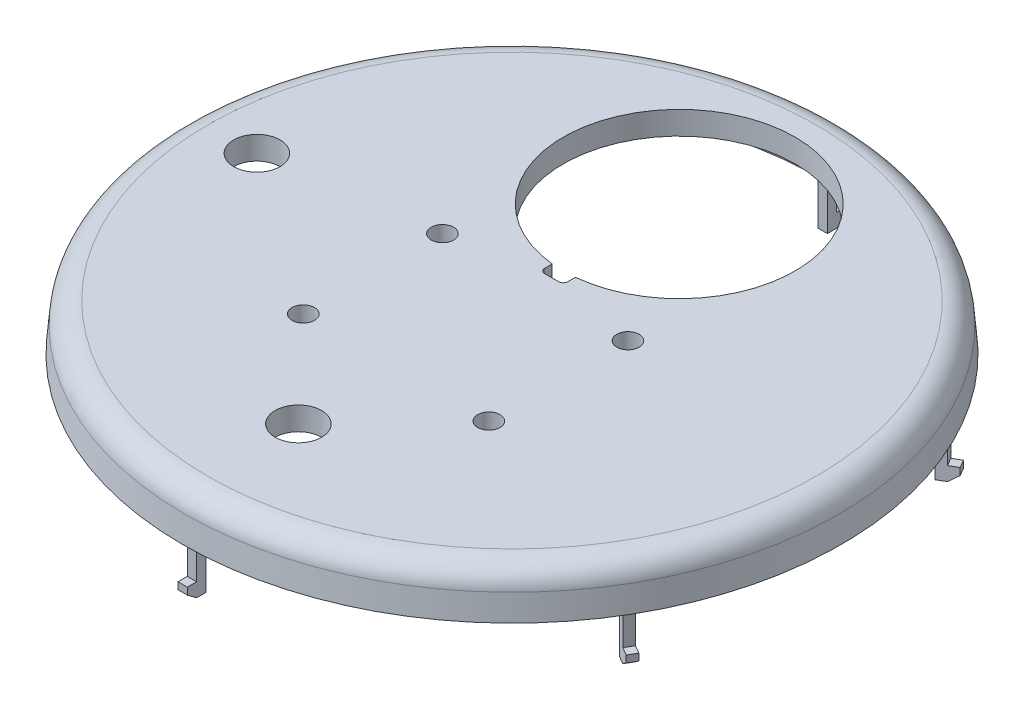
from build123d import *

# Parameters (mm, degrees)
SKETCH1_R           = 71.05
BOSS_EXTRUDE1_DEPTH = 10
BOSS_EXTRUDE1_TAPER = 5
SHELL4_T            = -5
SKETCH2_R           = 5
SKETCH2_R_2         = 25
SKETCH2_R_3         = 2.413
CUT_EXTRUDE1_DEPTH  = 101.976259737
CUT_EXTRUDE4_DEPTH  = 10
FILLET2_R           = 5
SKETCH11_R          = 5
CUT_EXTRUDE8_DEPTH  = 101.976259737
SKETCH12_W          = 2
SKETCH12_H          = 2
BOSS_EXTRUDE4_DEPTH = 7.5
SKETCH13_W          = 2
SKETCH13_H          = 4
BOSS_EXTRUDE5_DEPTH = 3
CUT_EXTRUDE9_DEPTH  = 3
CUT_EXTRUDE10_DEPTH = 3
CUT_EXTRUDE11_DEPTH = 3
CUT_EXTRUDE12_DEPTH = 3
CUT_EXTRUDE13_DEPTH = 3
CUT_EXTRUDE14_DEPTH = 3


with BuildPart() as part:
    # Sketch1 → Boss-Extrude1 (new body)
    with BuildSketch(Plane(origin=(0, 0, 0), x_dir=(1, 0, 0), z_dir=(0, 1, 0))):
        Circle(SKETCH1_R)
    extrude(amount=BOSS_EXTRUDE1_DEPTH, taper=BOSS_EXTRUDE1_TAPER)

    # Shell4
    shell4_openings = [part.faces().sort_by_distance(p)[0] for p in [
        (0, 0, 0),
    ]]
    offset(amount=SHELL4_T, openings=shell4_openings, kind=Kind.INTERSECTION)

    # Sketch2 → Cut-Extrude1 (cut, through all)
    with BuildSketch(Plane(origin=(0, 10, 0), x_dir=(1, 0, 0), z_dir=(0, 1, 0))):
        with Locations(Location((0, -46.05, 0), (0, 0, 270))):
            Circle(SKETCH2_R)
        with Locations(Location((0, 36.05, 0), (0, 0, 270))):
            Circle(SKETCH2_R_2)
        with Locations(Location((20, 5, 0), (0, 0, 270))):
            Circle(SKETCH2_R_3)
        with Locations(Location((20, -25, 0), (0, 0, 270))):
            Circle(SKETCH2_R_3)
        with Locations(Location((-20, -25, 0), (0, 0, 270))):
            Circle(SKETCH2_R_3)
        with Locations(Location((-20, 5, 0), (0, 0, 270))):
            Circle(SKETCH2_R_3)
    extrude(amount=-CUT_EXTRUDE1_DEPTH, mode=Mode.SUBTRACT)

    # Sketch6 → Cut-Extrude4 (cut)
    with BuildSketch(Plane(origin=(0, 10, 0), x_dir=(1, 0, 0), z_dir=(0, 1, 0))):
        with BuildLine():
            Line((-2.5, 14.187111582), (2.5, 14.187111582))
            Line((2.5, 14.187111582), (2.5, 9.55))
            ThreePointArc((2.5, 9.55), (2.207106781, 8.842893219), (1.5, 8.55))
            Line((1.5, 8.55), (-1.5, 8.55))
            ThreePointArc((-1.5, 8.55), (-2.207106781, 8.842893219), (-2.5, 9.55))
            Line((-2.5, 9.55), (-2.5, 14.187111582))
        make_face()
    extrude(amount=-CUT_EXTRUDE4_DEPTH, mode=Mode.SUBTRACT)

    # Fillet2
    fillet2_edges = [part.edges().sort_by_distance(p)[0] for p in [
        (-70.175113365, 10, 0),
    ]]
    fillet(fillet2_edges, radius=FILLET2_R)

    # Sketch11 → Cut-Extrude8 (cut, through all)
    with BuildSketch(Plane(origin=(0, 10, 0), x_dir=(1, 0, 0), z_dir=(0, 1, 0))):
        with Locations(Location((-55, 0, 0), (0, 0, 270))):
            Circle(SKETCH11_R)
    extrude(amount=-CUT_EXTRUDE8_DEPTH, mode=Mode.SUBTRACT)

    # Sketch12 → Boss-Extrude4 (add)
    with BuildSketch(Plane(origin=(0, 0, 0), x_dir=(-1, 0, 0), z_dir=(0, -1, 0))):
        Polygon((58.523702054, 32.633974596), (60.255752861, 33.633974596), (59.255752861, 35.366025404), (57.523702054, 34.366025404), align=None)
        with Locations((0, 68)):
            Rectangle(SKETCH12_W, SKETCH12_H)
        Polygon((57.523702054, -34.366025404), (59.255752861, -35.366025404), (60.255752861, -33.633974596), (58.523702054, -32.633974596), align=None)
        with Locations((0, -68)):
            Rectangle(SKETCH12_W, SKETCH12_H)
        Polygon((-58.523702054, -32.633974596), (-60.255752861, -33.633974596), (-59.255752861, -35.366025404), (-57.523702054, -34.366025404), align=None)
        Polygon((-57.523702054, 34.366025404), (-59.255752861, 35.366025404), (-60.255752861, 33.633974596), (-58.523702054, 32.633974596), align=None)
    extrude(amount=BOSS_EXTRUDE4_DEPTH)

    # Sketch13 → Boss-Extrude5 (add)
    with BuildSketch(Plane(origin=(0, -7.5, 0), x_dir=(-1, 0, 0), z_dir=(0, -1, 0))):
        Polygon((-58.523702054, -32.633974596), (-61.987803669, -34.633974596), (-60.987803669, -36.366025404), (-57.523702054, -34.366025404), align=None)
        with Locations((0, -69)):
            Rectangle(SKETCH13_W, SKETCH13_H)
        Polygon((-57.523702054, 34.366025404), (-60.987803669, 36.366025404), (-61.987803669, 34.633974596), (-58.523702054, 32.633974596), align=None)
        with Locations((0, 69)):
            Rectangle(SKETCH13_W, SKETCH13_H)
        Polygon((58.523702054, 32.633974596), (61.987803669, 34.633974596), (60.987803669, 36.366025404), (57.523702054, 34.366025404), align=None)
        Polygon((57.523702054, -34.366025404), (60.987803669, -36.366025404), (61.987803669, -34.633974596), (58.523702054, -32.633974596), align=None)
    extrude(amount=BOSS_EXTRUDE5_DEPTH)

    # Sketch14 → Cut-Extrude9 (cut)
    with BuildSketch(Plane(origin=(1, 0, 0), x_dir=(0, 0, -1), z_dir=(1, 0, 0))):
        Polygon((71, -9), (69, -10.5), (71, -10.5), align=None)
    extrude(amount=-CUT_EXTRUDE9_DEPTH, mode=Mode.SUBTRACT)

    # Sketch16 → Cut-Extrude10 (cut)
    with BuildSketch(Plane(origin=(0.5000000000007515, 0, 0.8660254037857402), x_dir=(0.8660254037844386, 0, -0.4999999999999999), z_dir=(0.49999999999999994, 0, 0.8660254037844387))):
        Polygon((71, -9), (69, -10.5), (71, -10.5), align=None)
    extrude(amount=-CUT_EXTRUDE10_DEPTH, mode=Mode.SUBTRACT)

    # Sketch17 → Cut-Extrude11 (cut)
    with BuildSketch(Plane(origin=(-0.5000000000021357, 0, 0.8660254037881377), x_dir=(0.8660254037844386, 0, 0.4999999999999999), z_dir=(-0.49999999999999994, 0, 0.8660254037844387))):
        Polygon((71, -9), (69, -10.5), (71, -10.5), align=None)
    extrude(amount=-CUT_EXTRUDE11_DEPTH, mode=Mode.SUBTRACT)

    # Sketch18 → Cut-Extrude12 (cut)
    with BuildSketch(Plane.ZY.offset(1)):
        Polygon((71, -9), (69, -10.5), (71, -10.5), align=None)
    extrude(amount=-CUT_EXTRUDE12_DEPTH, mode=Mode.SUBTRACT)

    # Sketch19 → Cut-Extrude13 (cut)
    with BuildSketch(Plane(origin=(-0.5000000000020854, 0, -0.8660254037880506), x_dir=(-0.8660254037844386, 0, 0.4999999999999999), z_dir=(-0.49999999999999994, 0, -0.8660254037844387))):
        Polygon((71, -9), (69, -10.5), (71, -10.5), align=None)
    extrude(amount=-CUT_EXTRUDE13_DEPTH, mode=Mode.SUBTRACT)

    # Sketch20 → Cut-Extrude14 (cut)
    with BuildSketch(Plane(origin=(0.5000000000006769, 0, -0.8660254037856109), x_dir=(-0.8660254037844386, 0, -0.4999999999999999), z_dir=(0.49999999999999994, 0, -0.8660254037844387))):
        Polygon((71, -9), (69, -10.5), (71, -10.5), align=None)
    extrude(amount=-CUT_EXTRUDE14_DEPTH, mode=Mode.SUBTRACT)


solid = part.part
